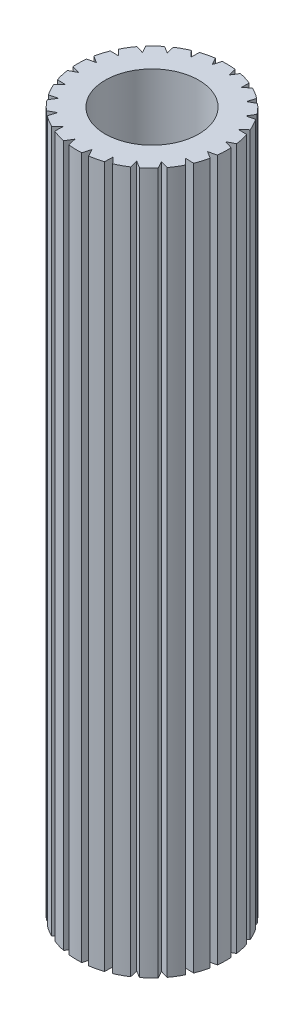
from build123d import *

# Parameters (mm, degrees)
SKETCH_1_R      = 1
EXTRUDE_1_DEPTH = 15


with BuildPart() as part:
    # 草图1 → 凸台-拉伸1 (new body)
    with BuildSketch(Plane(origin=(0, 0, 0), x_dir=(1, 0, 0), z_dir=(0, 1, 0))):
        with BuildLine():
            Line((-0.228121034, 1.583654253), (-0.144036994, 1.429143956))
            Line((-0.144036994, 1.429143956), (-0.094428358, 1.597211096))
            ThreePointArc((-0.094428358, 1.597211096), (0.047740264, 1.599287612), (0.189531883, 1.588734611))
            Line((0.189531883, 1.588734611), (0.230760622, 1.417726573))
            Line((0.230760622, 1.417726573), (0.322177861, 1.567227305))
            ThreePointArc((0.322177861, 1.567227305), (0.460039647, 1.532437119), (0.594268516, 1.485545331))
            Line((0.594268516, 1.485545331), (0.589832282, 1.309693468))
            Line((0.589832282, 1.309693468), (0.716828191, 1.430439563))
            ThreePointArc((0.716828191, 1.430439563), (0.840988088, 1.361153568), (0.958506731, 1.281118592))
            Line((0.958506731, 1.281118592), (0.908707847, 1.112406917))
            Line((0.908707847, 1.112406917), (1.062627865, 1.196169729))
            ThreePointArc((1.062627865, 1.196169729), (1.16462458, 1.097109651), (1.257424297, 0.989385738))
            Line((1.257424297, 0.989385738), (1.165656474, 0.839311673))
            Line((1.165656474, 0.839311673), (1.336011205, 0.880382905))
            ThreePointArc((1.336011205, 0.880382905), (1.408893832, 0.758299525), (1.470650475, 0.63022788))
            Line((1.470650475, 0.63022788), (1.343167539, 0.509018726))
            Line((1.343167539, 0.509018726), (1.51834759, 0.504599441))
            ThreePointArc((1.51834759, 0.504599441), (1.557149298, 0.367812539), (1.583654253, 0.228121034))
            Line((1.583654253, 0.228121034), (1.429143956, 0.144036994))
            Line((1.429143956, 0.144036994), (1.597211096, 0.094428358))
            ThreePointArc((1.597211096, 0.094428358), (1.599287612, -0.047740264), (1.588734611, -0.189531883))
            Line((1.588734611, -0.189531883), (1.417726573, -0.230760622))
            Line((1.417726573, -0.230760622), (1.567227305, -0.322177861))
            ThreePointArc((1.567227305, -0.322177861), (1.532437119, -0.460039647), (1.485545331, -0.594268516))
            Line((1.485545331, -0.594268516), (1.309693468, -0.589832282))
            Line((1.309693468, -0.589832282), (1.430439563, -0.716828191))
            ThreePointArc((1.430439563, -0.716828191), (1.361153568, -0.840988088), (1.281118592, -0.958506731))
            Line((1.281118592, -0.958506731), (1.112406917, -0.908707847))
            Line((1.112406917, -0.908707847), (1.196169729, -1.062627865))
            ThreePointArc((1.196169729, -1.062627865), (1.097109651, -1.16462458), (0.989385738, -1.257424297))
            Line((0.989385738, -1.257424297), (0.839311673, -1.165656474))
            Line((0.839311673, -1.165656474), (0.880382905, -1.336011205))
            ThreePointArc((0.880382905, -1.336011205), (0.758299525, -1.408893832), (0.63022788, -1.470650475))
            Line((0.63022788, -1.470650475), (0.509018726, -1.343167539))
            Line((0.509018726, -1.343167539), (0.504599441, -1.51834759))
            ThreePointArc((0.504599441, -1.51834759), (0.367812539, -1.557149298), (0.228121034, -1.583654253))
            Line((0.228121034, -1.583654253), (0.144036994, -1.429143956))
            Line((0.144036994, -1.429143956), (0.094428358, -1.597211096))
            ThreePointArc((0.094428358, -1.597211096), (-0.047740264, -1.599287612), (-0.189531883, -1.588734611))
            Line((-0.189531883, -1.588734611), (-0.230760622, -1.417726573))
            Line((-0.230760622, -1.417726573), (-0.322177861, -1.567227305))
            ThreePointArc((-0.322177861, -1.567227305), (-0.460039647, -1.532437119), (-0.594268516, -1.485545331))
            Line((-0.594268516, -1.485545331), (-0.589832282, -1.309693468))
            Line((-0.589832282, -1.309693468), (-0.716828191, -1.430439563))
            ThreePointArc((-0.716828191, -1.430439563), (-0.840988088, -1.361153568), (-0.958506731, -1.281118592))
            Line((-0.958506731, -1.281118592), (-0.908707847, -1.112406917))
            Line((-0.908707847, -1.112406917), (-1.062627865, -1.196169729))
            ThreePointArc((-1.062627865, -1.196169729), (-1.16462458, -1.097109651), (-1.257424297, -0.989385738))
            Line((-1.257424297, -0.989385738), (-1.165656474, -0.839311673))
            Line((-1.165656474, -0.839311673), (-1.336011205, -0.880382905))
            ThreePointArc((-1.336011205, -0.880382905), (-1.408893832, -0.758299525), (-1.470650475, -0.63022788))
            Line((-1.470650475, -0.63022788), (-1.343167539, -0.509018726))
            Line((-1.343167539, -0.509018726), (-1.51834759, -0.504599441))
            ThreePointArc((-1.51834759, -0.504599441), (-1.557149298, -0.367812539), (-1.583654253, -0.228121034))
            Line((-1.583654253, -0.228121034), (-1.429143956, -0.144036994))
            Line((-1.429143956, -0.144036994), (-1.597211096, -0.094428358))
            ThreePointArc((-1.597211096, -0.094428358), (-1.599287612, 0.047740264), (-1.588734611, 0.189531883))
            Line((-1.588734611, 0.189531883), (-1.417726573, 0.230760622))
            Line((-1.417726573, 0.230760622), (-1.567227305, 0.322177861))
            ThreePointArc((-1.567227305, 0.322177861), (-1.532437119, 0.460039647), (-1.485545331, 0.594268516))
            Line((-1.485545331, 0.594268516), (-1.309693468, 0.589832282))
            Line((-1.309693468, 0.589832282), (-1.430439563, 0.716828191))
            ThreePointArc((-1.430439563, 0.716828191), (-1.361153568, 0.840988088), (-1.281118592, 0.958506731))
            Line((-1.281118592, 0.958506731), (-1.112406917, 0.908707847))
            Line((-1.112406917, 0.908707847), (-1.196169729, 1.062627865))
            ThreePointArc((-1.196169729, 1.062627865), (-1.097109651, 1.16462458), (-0.989385738, 1.257424297))
            Line((-0.989385738, 1.257424297), (-0.839311673, 1.165656474))
            Line((-0.839311673, 1.165656474), (-0.880382905, 1.336011205))
            ThreePointArc((-0.880382905, 1.336011205), (-0.758299525, 1.408893832), (-0.63022788, 1.470650475))
            Line((-0.63022788, 1.470650475), (-0.509018726, 1.343167539))
            Line((-0.509018726, 1.343167539), (-0.504599441, 1.51834759))
            ThreePointArc((-0.504599441, 1.51834759), (-0.367812539, 1.557149298), (-0.228121034, 1.583654253))
        make_face()
        Circle(SKETCH_1_R, mode=Mode.SUBTRACT)
    extrude(amount=EXTRUDE_1_DEPTH)


solid = part.part
